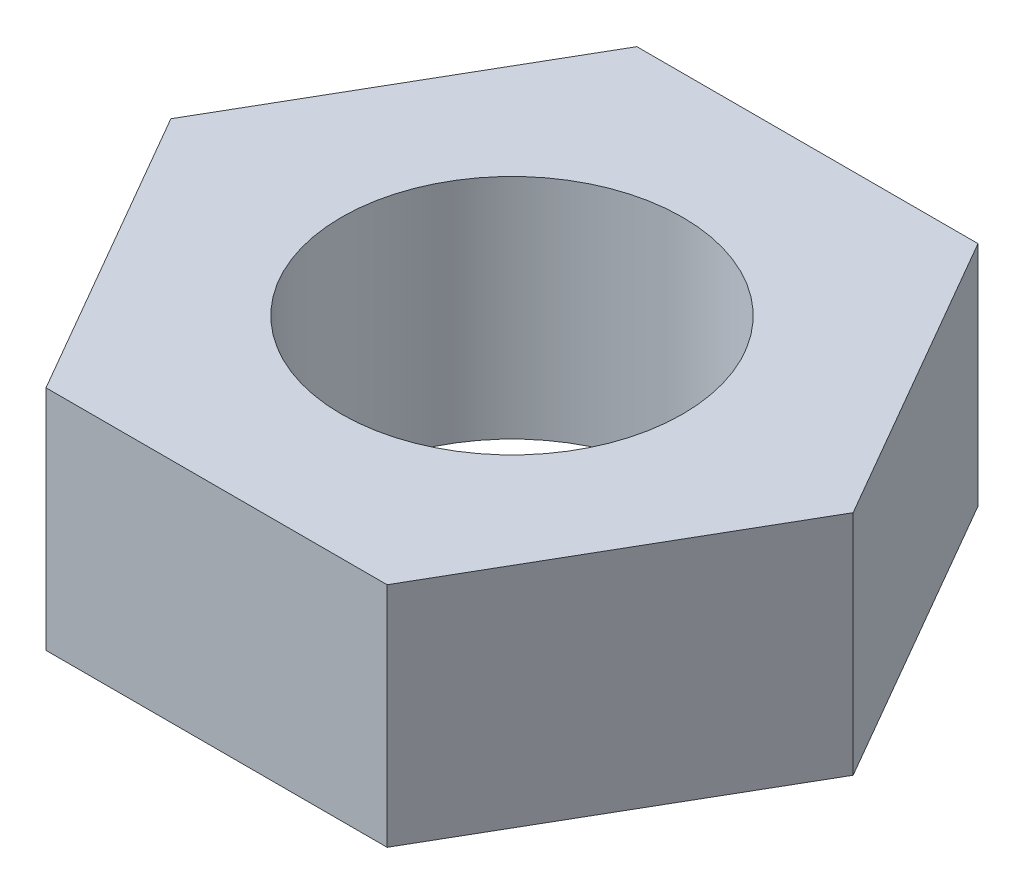
from build123d import *

# Parameters (mm, degrees)
EXTRUDE_1_DEPTH     = 1
SKETCH_2_R          = 0.75
CUT_EXTRUDE_1_DEPTH = 2


with BuildPart() as part:
    # 草图1 → 凸台-拉伸1 (new body)
    with BuildSketch(Plane(origin=(0, 0, 0), x_dir=(1, 0, 0), z_dir=(0, 1, 0))):
        Polygon((-3.117219624, 2.625987541), (-2.367219624, 1.326949435), (-0.867219624, 1.326949435), (-0.117219624, 2.625987541), (-0.867219624, 3.925025646), (-2.367219624, 3.925025646), align=None)
    extrude(amount=EXTRUDE_1_DEPTH)

    # 草图2 → 切除-拉伸1 (cut)
    with BuildSketch(Plane(origin=(0, 1, 0), x_dir=(1, 0, 0), z_dir=(0, 1, 0))):
        with Locations((-1.617219624, 2.625987541)):
            Circle(SKETCH_2_R)
    extrude(amount=-CUT_EXTRUDE_1_DEPTH, mode=Mode.SUBTRACT)


solid = part.part
